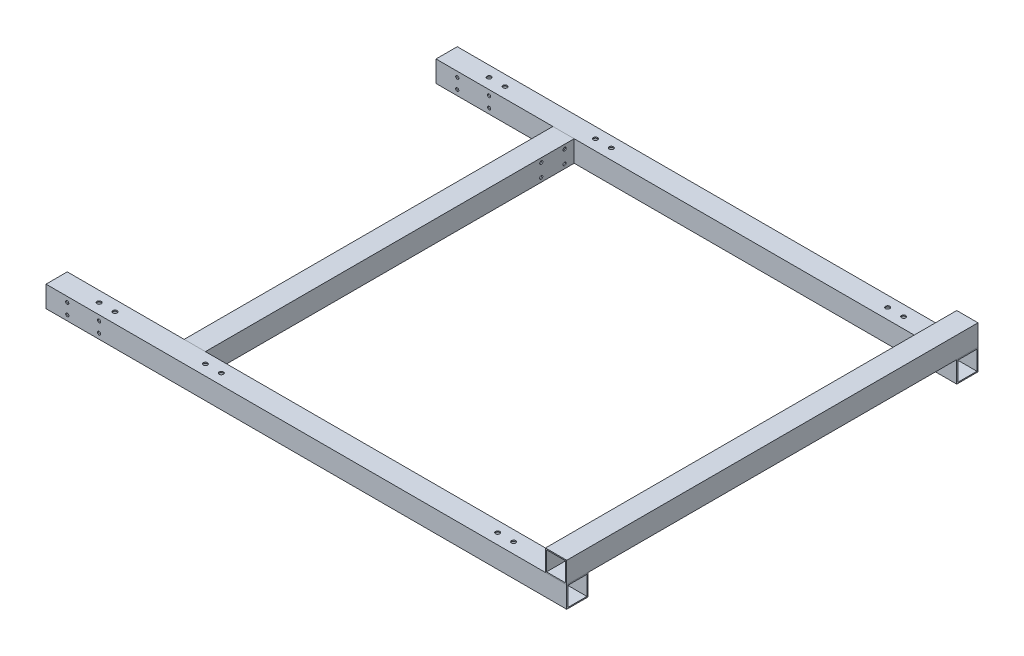
from build123d import *

# Parameters (mm, degrees)
SKETCH_11_W                 = 20
SKETCH_11_H                 = 20
SKETCH_11_W_2               = 18
SKETCH_11_H_2               = 18
F_20X20X1_1_DEPTH           = 500
SKETCH_11_ON_SEGMENT_2_W    = 20
SKETCH_11_ON_SEGMENT_2_H    = 20
SKETCH_11_ON_SEGMENT_2_W_2  = 18
SKETCH_11_ON_SEGMENT_2_H_2  = 18
F_20X20X1_1_2_DEPTH         = 515.142135624
SKETCH_11_ON_SEGMENT_3_W    = 20
SKETCH_11_ON_SEGMENT_3_H    = 20
SKETCH_11_ON_SEGMENT_3_W_2  = 18
SKETCH_11_ON_SEGMENT_3_H_2  = 18
F_20X20X1_1_3_DEPTH         = 110.284271247
SKETCH_11_ON_SEGMENT_4_W    = 20
SKETCH_11_ON_SEGMENT_4_H    = 20
SKETCH_11_ON_SEGMENT_4_W_2  = 18
SKETCH_11_ON_SEGMENT_4_H_2  = 18
F_20X20X1_1_4_DEPTH         = 515.142135624
SKETCH_11_ON_SEGMENT_5_W    = 20
SKETCH_11_ON_SEGMENT_5_H    = 20
SKETCH_11_ON_SEGMENT_5_W_2  = 18
SKETCH_11_ON_SEGMENT_5_H_2  = 18
F_20X20X1_1_5_DEPTH         = 369
SKETCH_11_ON_SEGMENT_6_W    = 20
SKETCH_11_ON_SEGMENT_6_H    = 20
SKETCH_11_ON_SEGMENT_6_W_2  = 18
SKETCH_11_ON_SEGMENT_6_H_2  = 18
F_20X20X1_1_6_DEPTH         = 82
SKETCH_12_R                 = 1.5
CUT_EXTRUDE_1_DEPTH         = 633.35195896
SKETCH_14_W                 = 20
SKETCH_14_H                 = 20
SKETCH_14_W_2               = 18
SKETCH_14_H_2               = 18
F_20X20X1_2_DEPTH           = 165.142135624
SKETCH_14_ON_SEGMENT_2_W    = 20
SKETCH_14_ON_SEGMENT_2_H    = 20
SKETCH_14_ON_SEGMENT_2_W_2  = 18
SKETCH_14_ON_SEGMENT_2_H_2  = 18
F_20X20X1_2_2_DEPTH         = 477.284271247
SKETCH_14_ON_SEGMENT_3_W    = 20
SKETCH_14_ON_SEGMENT_3_H    = 20
SKETCH_14_ON_SEGMENT_3_W_2  = 18
SKETCH_14_ON_SEGMENT_3_H_2  = 18
F_20X20X1_2_3_DEPTH         = 165.142135624
SKETCH_14_ON_SEGMENT_4_W    = 20
SKETCH_14_ON_SEGMENT_4_H    = 20
SKETCH_14_ON_SEGMENT_4_W_2  = 18
SKETCH_14_ON_SEGMENT_4_H_2  = 18
F_20X20X1_2_4_DEPTH         = 151
SKETCH_16_W                 = 20
SKETCH_16_H                 = 20
SKETCH_16_W_2               = 18
SKETCH_16_H_2               = 18
F_20X20X1_3_DEPTH           = 467
SKETCH_110_W                = 20
SKETCH_110_H                = 20
SKETCH_110_W_2              = 18
SKETCH_110_H_2              = 18
F_20X20X1_4_DEPTH           = 360
SKETCH_110_ON_SEGMENT_2_W   = 20
SKETCH_110_ON_SEGMENT_2_H   = 20
SKETCH_110_ON_SEGMENT_2_W_2 = 18
SKETCH_110_ON_SEGMENT_2_H_2 = 18
F_20X20X1_4_2_DEPTH         = 360
SKETCH_111_R                = 6
CUT_EXTRUDE_3_DEPTH         = 804.024906214
SKETCH_17_R                 = 1.5
CUT_EXTRUDE_5_DEPTH         = 693.927846172
CUT_EXTRUDE_7_DEPTH         = 80
SKETCH_114_R                = 2
CUT_EXTRUDE_8_DEPTH         = 762.136650018
SKETCH_115_R                = 2
CUT_EXTRUDE_9_DEPTH         = 762.136650018
SKETCH_116_W                = 20
SKETCH_116_H                = 20
CUT_EXTRUDE_10_DEPTH        = 766.682048895
SKETCH_117_W                = 463.793708678
SKETCH_117_H                = 112.242217969
CUT_EXTRUDE_11_DEPTH        = 220
SKETCH_118_W                = 249.609075219
SKETCH_118_H                = 20
CUT_EXTRUDE_12_DEPTH        = 393


with BuildPart() as part:
    # 草图11 → 铝管 20X20X1(1) (new body)
    with BuildSketch(Plane(origin=(0, 0, 0), x_dir=(0, 0, -1), z_dir=(1, 0, 0))):
        Rectangle(SKETCH_11_W, SKETCH_11_H)
        Rectangle(SKETCH_11_W_2, SKETCH_11_H_2, mode=Mode.SUBTRACT)
    extrude(amount=F_20X20X1_1_DEPTH)


with BuildPart() as body_2:
    # 草图11 on segment 2 (carried to segment 2) → 20X20X1_1 2 (new body)
    with BuildSketch(Plane(origin=(-15.142135624, 0, 447), x_dir=(0, 0, -1), z_dir=(1, 0, 0))):
        Rectangle(SKETCH_11_ON_SEGMENT_2_W, SKETCH_11_ON_SEGMENT_2_H)
        Rectangle(SKETCH_11_ON_SEGMENT_2_W_2, SKETCH_11_ON_SEGMENT_2_H_2, mode=Mode.SUBTRACT)
    extrude(amount=F_20X20X1_1_2_DEPTH)

    # 20X20X1_1 2 mitre 1
    split(bisect_by=Plane(origin=(0, 0, 447), x_dir=(0, 1, 0), z_dir=(0.707106781, 0, 0.707106781)), keep=Keep.TOP)


with BuildPart() as body_3:
    # 草图11 on segment 3 (carried to segment 3) → 20X20X1_1 3 (new body)
    with BuildSketch(Plane.XY.offset(351.857864376)):
        Rectangle(SKETCH_11_ON_SEGMENT_3_W, SKETCH_11_ON_SEGMENT_3_H)
        Rectangle(SKETCH_11_ON_SEGMENT_3_W_2, SKETCH_11_ON_SEGMENT_3_H_2, mode=Mode.SUBTRACT)
    extrude(amount=F_20X20X1_1_3_DEPTH)

    # 20X20X1_1 3 mitre 1
    split(bisect_by=Plane(origin=(0, 0, 367), x_dir=(0, -1, 0), z_dir=(-0.707106781, 0, 0.707106781)), keep=Keep.TOP)

    # 20X20X1_1 3 mitre 2
    split(bisect_by=Plane(origin=(0, 0, 447), x_dir=(0, -1, 0), z_dir=(-0.707106781, 0, -0.707106781)), keep=Keep.TOP)


with BuildPart() as body_4:
    # 草图11 on segment 4 (carried to segment 4) → 20X20X1_1 4 (new body)
    with BuildSketch(Plane(origin=(-15.142135624, 0, 367), x_dir=(0, 0, -1), z_dir=(1, 0, 0))):
        Rectangle(SKETCH_11_ON_SEGMENT_4_W, SKETCH_11_ON_SEGMENT_4_H)
        Rectangle(SKETCH_11_ON_SEGMENT_4_W_2, SKETCH_11_ON_SEGMENT_4_H_2, mode=Mode.SUBTRACT)
    extrude(amount=F_20X20X1_1_4_DEPTH)

    # 20X20X1_1 4 mitre 1
    split(bisect_by=Plane(origin=(0, 0, 367), x_dir=(0, 1, 0), z_dir=(0.707106781, 0, -0.707106781)), keep=Keep.TOP)


with BuildPart() as body_5:
    # 草图11 on segment 5 (carried to segment 5) → 20X20X1_1 5 (new body)
    with BuildSketch(Plane(origin=(130, 0, -1), x_dir=(1, 0, 0), z_dir=(0, 0, 1))):
        Rectangle(SKETCH_11_ON_SEGMENT_5_W, SKETCH_11_ON_SEGMENT_5_H)
        Rectangle(SKETCH_11_ON_SEGMENT_5_W_2, SKETCH_11_ON_SEGMENT_5_H_2, mode=Mode.SUBTRACT)
    extrude(amount=F_20X20X1_1_5_DEPTH)

    # 20X20X1_1 5 mitre 1
    split(bisect_by=Plane(origin=(130, 0, 367), x_dir=(0, 1, 0), z_dir=(0, 0, -1)), keep=Keep.TOP)

    # 20X20X1_1 5 mitre 2
    split(bisect_by=Plane(origin=(130, 0, 10), x_dir=(0, -1, 0), z_dir=(0, 0, 1)), keep=Keep.TOP)

    # 20X20X1_1 5 mitre 3
    split(bisect_by=Plane(origin=(130, 0, 357), x_dir=(0, 1, 0), z_dir=(0, 0, -1)), keep=Keep.TOP)

    # 草图17 → 切除-拉伸5 (cut, through all)
    with BuildSketch(Plane(origin=(140, 0, 0), x_dir=(0, 0, -1), z_dir=(1, 0, 0))):
        with Locations((-41, 6)):
            Circle(SKETCH_17_R)
        with Locations((-41, -6)):
            Circle(SKETCH_17_R)
        with Locations((-19, 6)):
            Circle(SKETCH_17_R)
        with Locations((-19, -6)):
            Circle(SKETCH_17_R)
    extrude(amount=-CUT_EXTRUDE_5_DEPTH, mode=Mode.SUBTRACT)


with BuildPart() as body_6:
    # 草图11 on segment 6 (carried to segment 6) → 20X20X1_1 6 (new body)
    with BuildSketch(Plane(origin=(130, 0, 366), x_dir=(1, 0, 0), z_dir=(0, 0, 1))):
        Rectangle(SKETCH_11_ON_SEGMENT_6_W, SKETCH_11_ON_SEGMENT_6_H)
        Rectangle(SKETCH_11_ON_SEGMENT_6_W_2, SKETCH_11_ON_SEGMENT_6_H_2, mode=Mode.SUBTRACT)
    extrude(amount=F_20X20X1_1_6_DEPTH)

    # 20X20X1_1 6 mitre 1
    split(bisect_by=Plane(origin=(130, 0, 367), x_dir=(0, -1, 0), z_dir=(0, 0, 1)), keep=Keep.TOP)

    # 20X20X1_1 6 mitre 2
    split(bisect_by=Plane(origin=(130, 0, 377), x_dir=(0, -1, 0), z_dir=(0, 0, 1)), keep=Keep.TOP)

    # 20X20X1_1 6 mitre 3
    split(bisect_by=Plane(origin=(130, 0, 437), x_dir=(0, 1, 0), z_dir=(0, 0, -1)), keep=Keep.TOP)


with BuildPart() as cut_extrude_1_tool:
    # 草图12 → 切除-拉伸1 (new, through all)
    with BuildSketch(Plane.XY.offset(377)):
        with Locations((30, 5)):
            Circle(SKETCH_12_R)
        with Locations((60, 5)):
            Circle(SKETCH_12_R)
        with Locations((30, -5)):
            Circle(SKETCH_12_R)
        with Locations((60, -5)):
            Circle(SKETCH_12_R)
    extrude(amount=-CUT_EXTRUDE_1_DEPTH)


with BuildPart() as part_1:
    add(part.part)

    # 切除-拉伸1: cut by cut_extrude_1_tool
    add(cut_extrude_1_tool.part, mode=Mode.SUBTRACT)

    # 草图115 → 切除-拉伸9 (cut, through all)
    with BuildSketch(Plane.XZ.offset(10)):
        with Locations(Location((50, 0, 0), (0, 0, 270))):
            Circle(SKETCH_115_R)
        with Locations(Location((65, 0, 0), (0, 0, 270))):
            Circle(SKETCH_115_R)
        with Locations(Location((150, 0, 0), (0, 0, 270))):
            Circle(SKETCH_115_R)
        with Locations(Location((165, 0, 0), (0, 0, 270))):
            Circle(SKETCH_115_R)
        with Locations(Location((440, 0, 0), (0, 0, 270))):
            Circle(SKETCH_115_R)
        with Locations(Location((425, 0, 0), (0, 0, 270))):
            Circle(SKETCH_115_R)
    extrude(amount=-CUT_EXTRUDE_9_DEPTH, mode=Mode.SUBTRACT)


with BuildPart() as body_4_1:
    add(body_4.part)

    # 切除-拉伸1: cut by cut_extrude_1_tool
    add(cut_extrude_1_tool.part, mode=Mode.SUBTRACT)

    # 草图114 → 切除-拉伸8 (cut, through all)
    with BuildSketch(Plane.XZ.offset(10)):
        with Locations(Location((49.999999674, 367.000008181, 0), (0, 0, 270))):
            Circle(SKETCH_114_R)
        with Locations(Location((64.999999674, 367.000008181, 0), (0, 0, 270))):
            Circle(SKETCH_114_R)
        with Locations(Location((149.999999674, 367.000008181, 0), (0, 0, 270))):
            Circle(SKETCH_114_R)
        with Locations(Location((164.999999674, 367.000008181, 0), (0, 0, 270))):
            Circle(SKETCH_114_R)
        with Locations(Location((424.999999674, 367.000008181, 0), (0, 0, 270))):
            Circle(SKETCH_114_R)
        with Locations(Location((439.999999674, 367.000008181, 0), (0, 0, 270))):
            Circle(SKETCH_114_R)
    extrude(amount=-CUT_EXTRUDE_8_DEPTH, mode=Mode.SUBTRACT)


with BuildPart() as body_7:
    # 草图14 → 铝管 20X20X1(2) (new body)
    with BuildSketch(Plane(origin=(500, 0, 447), x_dir=(0, 0, -1), z_dir=(1, 0, 0))):
        Rectangle(SKETCH_14_W, SKETCH_14_H)
        Rectangle(SKETCH_14_W_2, SKETCH_14_H_2, mode=Mode.SUBTRACT)
    extrude(amount=F_20X20X1_2_DEPTH)

    # 铝管 20X20X1(2) mitre 1
    split(bisect_by=Plane(origin=(650, 0, 447), x_dir=(0, -1, 0), z_dir=(-0.707106781, 0, 0.707106781)), keep=Keep.TOP)


with BuildPart() as body_8:
    # 草图14 on segment 2 (carried to segment 2) → 20X20X1_2 2 (new body)
    with BuildSketch(Plane(origin=(650, 0, 462.142135624), x_dir=(-1, 0, 0), z_dir=(0, 0, -1))):
        Rectangle(SKETCH_14_ON_SEGMENT_2_W, SKETCH_14_ON_SEGMENT_2_H)
        Rectangle(SKETCH_14_ON_SEGMENT_2_W_2, SKETCH_14_ON_SEGMENT_2_H_2, mode=Mode.SUBTRACT)
    extrude(amount=F_20X20X1_2_2_DEPTH)

    # 20X20X1_2 2 mitre 1
    split(bisect_by=Plane(origin=(650, 0, 447), x_dir=(0, 1, 0), z_dir=(0.707106781, 0, -0.707106781)), keep=Keep.TOP)

    # 20X20X1_2 2 mitre 2
    split(bisect_by=Plane(origin=(650, 0, 0), x_dir=(0, 1, 0), z_dir=(0.707106781, 0, 0.707106781)), keep=Keep.TOP)


with BuildPart() as body_9:
    # 草图14 on segment 3 (carried to segment 3) → 20X20X1_2 3 (new body)
    with BuildSketch(Plane.ZY.offset(-665.142135624)):
        Rectangle(SKETCH_14_ON_SEGMENT_3_W, SKETCH_14_ON_SEGMENT_3_H)
        Rectangle(SKETCH_14_ON_SEGMENT_3_W_2, SKETCH_14_ON_SEGMENT_3_H_2, mode=Mode.SUBTRACT)
    extrude(amount=F_20X20X1_2_3_DEPTH)

    # 20X20X1_2 3 mitre 1
    split(bisect_by=Plane(origin=(650, 0, 0), x_dir=(0, -1, 0), z_dir=(-0.707106781, 0, -0.707106781)), keep=Keep.TOP)


with BuildPart() as body_10:
    # 草图14 on segment 4 (carried to segment 4) → 20X20X1_2 4 (new body)
    with BuildSketch(Plane(origin=(500, 0, 367), x_dir=(0, 0, -1), z_dir=(1, 0, 0))):
        Rectangle(SKETCH_14_ON_SEGMENT_4_W, SKETCH_14_ON_SEGMENT_4_H)
        Rectangle(SKETCH_14_ON_SEGMENT_4_W_2, SKETCH_14_ON_SEGMENT_4_H_2, mode=Mode.SUBTRACT)
    extrude(amount=F_20X20X1_2_4_DEPTH)

    # 20X20X1_2 4 mitre 1
    split(bisect_by=Plane(origin=(640, 0, 367), x_dir=(0, -1, 0), z_dir=(-1, 0, 0)), keep=Keep.TOP)


with BuildPart() as body_11:
    # 草图16 → 铝管 20X20X1(3) (new body)
    with BuildSketch(Plane(origin=(490, 20, -10), x_dir=(1, 0, 0), z_dir=(0, 0, 1))):
        Rectangle(SKETCH_16_W, SKETCH_16_H)
        Rectangle(SKETCH_16_W_2, SKETCH_16_H_2, mode=Mode.SUBTRACT)
    extrude(amount=F_20X20X1_3_DEPTH)


with BuildPart() as body_12:
    # 草图110 → 铝管 20X20X1(4) (new body)
    with BuildSketch(Plane(origin=(140, 0, 100), x_dir=(0, 0, -1), z_dir=(1, 0, 0))):
        Rectangle(SKETCH_110_W, SKETCH_110_H)
        Rectangle(SKETCH_110_W_2, SKETCH_110_H_2, mode=Mode.SUBTRACT)
    extrude(amount=F_20X20X1_4_DEPTH)


with BuildPart() as body_13:
    # 草图110 on segment 2 (carried to segment 2) → 20X20X1_4 2 (new body)
    with BuildSketch(Plane(origin=(140, 0, 297), x_dir=(0, 0, -1), z_dir=(1, 0, 0))):
        Rectangle(SKETCH_110_ON_SEGMENT_2_W, SKETCH_110_ON_SEGMENT_2_H)
        Rectangle(SKETCH_110_ON_SEGMENT_2_W_2, SKETCH_110_ON_SEGMENT_2_H_2, mode=Mode.SUBTRACT)
    extrude(amount=F_20X20X1_4_2_DEPTH)


with BuildPart() as cut_extrude_3_tool:
    # 草图111 → 切除-拉伸3 (new, through all)
    with BuildSketch(Plane(origin=(0, 10, 0), x_dir=(1, 0, 0), z_dir=(0, 1, 0))):
        with Locations(Location((160, -100, 0), (0, 0, 270))):
            Circle(SKETCH_111_R)
        with Locations(Location((160, -297, 0), (0, 0, 270))):
            Circle(SKETCH_111_R)
        with Locations(Location((180, -100, 0), (0, 0, 270))):
            Circle(SKETCH_111_R)
        with Locations(Location((180, -297, 0), (0, 0, 270))):
            Circle(SKETCH_111_R)
        with Locations(Location((200, -100, 0), (0, 0, 270))):
            Circle(SKETCH_111_R)
        with Locations(Location((200, -297, 0), (0, 0, 270))):
            Circle(SKETCH_111_R)
        with Locations(Location((220, -100, 0), (0, 0, 270))):
            Circle(SKETCH_111_R)
        with Locations(Location((220, -297, 0), (0, 0, 270))):
            Circle(SKETCH_111_R)
        with Locations(Location((240, -100, 0), (0, 0, 270))):
            Circle(SKETCH_111_R)
        with Locations(Location((240, -297, 0), (0, 0, 270))):
            Circle(SKETCH_111_R)
        with Locations(Location((260, -100, 0), (0, 0, 270))):
            Circle(SKETCH_111_R)
        with Locations(Location((260, -297, 0), (0, 0, 270))):
            Circle(SKETCH_111_R)
        with Locations(Location((280, -100, 0), (0, 0, 270))):
            Circle(SKETCH_111_R)
        with Locations(Location((280, -297, 0), (0, 0, 270))):
            Circle(SKETCH_111_R)
        with Locations(Location((300, -100, 0), (0, 0, 270))):
            Circle(SKETCH_111_R)
        with Locations(Location((300, -297, 0), (0, 0, 270))):
            Circle(SKETCH_111_R)
        with Locations(Location((320, -100, 0), (0, 0, 270))):
            Circle(SKETCH_111_R)
        with Locations(Location((320, -297, 0), (0, 0, 270))):
            Circle(SKETCH_111_R)
        with Locations(Location((340, -100, 0), (0, 0, 270))):
            Circle(SKETCH_111_R)
        with Locations(Location((340, -297, 0), (0, 0, 270))):
            Circle(SKETCH_111_R)
        with Locations(Location((360, -100, 0), (0, 0, 270))):
            Circle(SKETCH_111_R)
        with Locations(Location((360, -297, 0), (0, 0, 270))):
            Circle(SKETCH_111_R)
        with Locations(Location((380, -100, 0), (0, 0, 270))):
            Circle(SKETCH_111_R)
        with Locations(Location((380, -297, 0), (0, 0, 270))):
            Circle(SKETCH_111_R)
        with Locations(Location((400, -100, 0), (0, 0, 270))):
            Circle(SKETCH_111_R)
        with Locations(Location((400, -297, 0), (0, 0, 270))):
            Circle(SKETCH_111_R)
        with Locations(Location((420, -100, 0), (0, 0, 270))):
            Circle(SKETCH_111_R)
        with Locations(Location((420, -297, 0), (0, 0, 270))):
            Circle(SKETCH_111_R)
        with Locations(Location((440, -100, 0), (0, 0, 270))):
            Circle(SKETCH_111_R)
        with Locations(Location((440, -297, 0), (0, 0, 270))):
            Circle(SKETCH_111_R)
    extrude(amount=-CUT_EXTRUDE_3_DEPTH)


with BuildPart() as body_12_1:
    add(body_12.part)

    # 切除-拉伸3: cut by cut_extrude_3_tool
    add(cut_extrude_3_tool.part, mode=Mode.SUBTRACT)


with BuildPart() as body_13_1:
    add(body_13.part)

    # 切除-拉伸3: cut by cut_extrude_3_tool
    add(cut_extrude_3_tool.part, mode=Mode.SUBTRACT)


with BuildPart() as cut_extrude_7_tool:
    # 草图113 → 切除-拉伸7 (new body)
    with BuildSketch(Plane.XY.offset(457)):
        Polygon((500, -10), (660, -10), (660, 10), (518.890990639, 10), (500, 10), align=None)
        Polygon((-10, -10), (500, -10), (500, 10), (418.532570431, 10), (-10, 10), align=None)
        Polygon((500, 10), (518.890990639, 10), (518.890990639, 44.57455739), (418.532570431, 44.57455739), (418.532570431, 10), align=None)
    extrude(amount=-CUT_EXTRUDE_7_DEPTH)


with BuildPart() as body_2_1:
    add(body_2.part)

    # 切除-拉伸7: cut by cut_extrude_7_tool
    add(cut_extrude_7_tool.part, mode=Mode.SUBTRACT)


with BuildPart() as body_3_1:
    add(body_3.part)

    # 切除-拉伸7: cut by cut_extrude_7_tool
    add(cut_extrude_7_tool.part, mode=Mode.SUBTRACT)


with BuildPart() as body_6_1:
    add(body_6.part)

    # 切除-拉伸7: cut by cut_extrude_7_tool
    add(cut_extrude_7_tool.part, mode=Mode.SUBTRACT)


with BuildPart() as body_7_1:
    add(body_7.part)

    # 切除-拉伸7: cut by cut_extrude_7_tool
    add(cut_extrude_7_tool.part, mode=Mode.SUBTRACT)


with BuildPart() as body_8_1:
    add(body_8.part)

    # 切除-拉伸7: cut by cut_extrude_7_tool
    add(cut_extrude_7_tool.part, mode=Mode.SUBTRACT)


with BuildPart() as body_11_1:
    add(body_11.part)

    # 切除-拉伸7: cut by cut_extrude_7_tool
    add(cut_extrude_7_tool.part, mode=Mode.SUBTRACT)


with BuildPart() as cut_extrude_10_tool:
    # 草图116 → 切除-拉伸10 (new, through all)
    with BuildSketch(Plane.XY.offset(377)):
        Rectangle(SKETCH_116_W, SKETCH_116_H)
    extrude(amount=-CUT_EXTRUDE_10_DEPTH)


with BuildPart() as part_2:
    add(part_1.part)

    # 切除-拉伸10: cut by cut_extrude_10_tool
    add(cut_extrude_10_tool.part, mode=Mode.SUBTRACT)


with BuildPart() as body_3_2:
    add(body_3_1.part)

    # 切除-拉伸10: cut by cut_extrude_10_tool
    add(cut_extrude_10_tool.part, mode=Mode.SUBTRACT)


with BuildPart() as body_4_2:
    add(body_4_1.part)

    # 切除-拉伸10: cut by cut_extrude_10_tool
    add(cut_extrude_10_tool.part, mode=Mode.SUBTRACT)


with BuildPart() as cut_extrude_11_tool:
    # 草图117 → 切除-拉伸11 (new body)
    with BuildSketch(Plane(origin=(500, 0, 0), x_dir=(0, 0, -1), z_dir=(1, 0, 0))):
        with Locations((-165.209666295, -10.864603229)):
            Rectangle(SKETCH_117_W, SKETCH_117_H)
    extrude(amount=CUT_EXTRUDE_11_DEPTH)


with BuildPart() as body_8_2:
    add(body_8_1.part)

    # 切除-拉伸11: cut by cut_extrude_11_tool
    add(cut_extrude_11_tool.part, mode=Mode.SUBTRACT)


with BuildPart() as body_9_1:
    add(body_9.part)

    # 切除-拉伸11: cut by cut_extrude_11_tool
    add(cut_extrude_11_tool.part, mode=Mode.SUBTRACT)


with BuildPart() as body_10_1:
    add(body_10.part)

    # 切除-拉伸11: cut by cut_extrude_11_tool
    add(cut_extrude_11_tool.part, mode=Mode.SUBTRACT)


with BuildPart() as cut_extrude_12_tool:
    # 草图118 → 切除-拉伸12 (new body)
    with BuildSketch(Plane(origin=(140, 0, 0), x_dir=(0, 0, -1), z_dir=(1, 0, 0))):
        with Locations((-193.88291518, 0)):
            Rectangle(SKETCH_118_W, SKETCH_118_H)
    extrude(amount=CUT_EXTRUDE_12_DEPTH)


with BuildPart() as body_12_2:
    add(body_12_1.part)

    # 切除-拉伸12: cut by cut_extrude_12_tool
    add(cut_extrude_12_tool.part, mode=Mode.SUBTRACT)


with BuildPart() as body_13_2:
    add(body_13_1.part)

    # 切除-拉伸12: cut by cut_extrude_12_tool
    add(cut_extrude_12_tool.part, mode=Mode.SUBTRACT)


solid = Compound([body_5.part, body_11_1.part, part_2.part, body_4_2.part])
